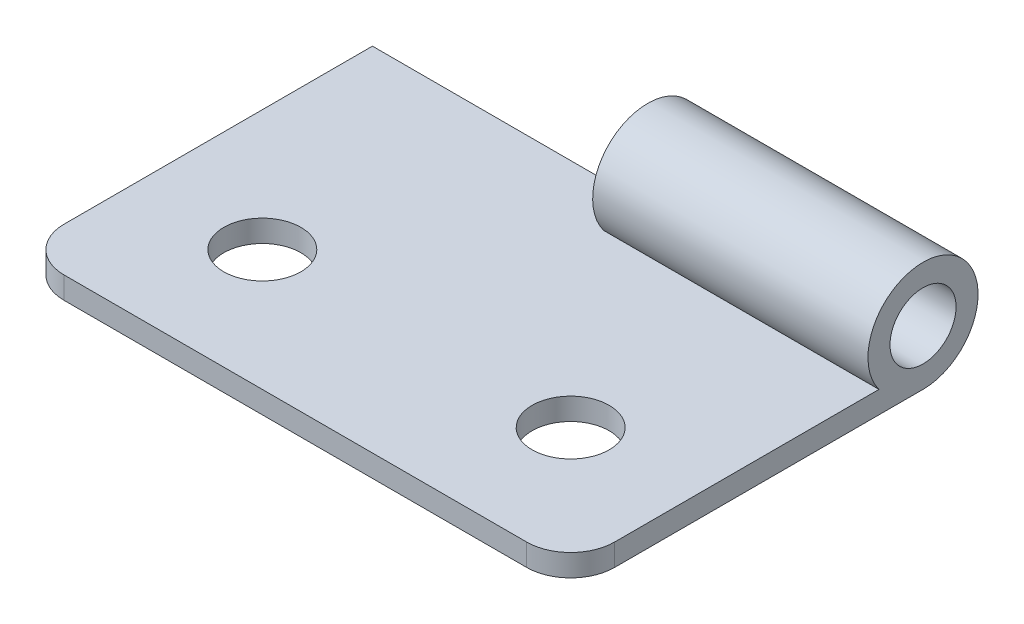
from build123d import *

# Parameters (mm, degrees)
SKETCH_1_W          = 25
SKETCH_1_H          = 16
EXTRUDE_1_DEPTH     = 1
SKETCH_2_R          = 1.75
CUT_EXTRUDE_1_DEPTH = 2
SKETCH_3_R          = 2.5
SKETCH_3_R_2        = 1.5
EXTRUDE_2_DEPTH     = 12.5
FILLET_1_R          = 2


with BuildPart() as part:
    # 草图1 → 凸台-拉伸1 (new body)
    with BuildSketch(Plane(origin=(0, 0, 0), x_dir=(1, 0, 0), z_dir=(0, 1, 0))):
        Rectangle(SKETCH_1_W, SKETCH_1_H)
    extrude(amount=EXTRUDE_1_DEPTH)

    # 草图2 → 切除-拉伸1 (cut, through all)
    with BuildSketch(Plane(origin=(0, 1, 0), x_dir=(1, 0, 0), z_dir=(0, 1, 0))):
        with Locations((-7, -2.5)):
            Circle(SKETCH_2_R)
        with Locations((7, -2.5)):
            Circle(SKETCH_2_R)
    extrude(amount=-CUT_EXTRUDE_1_DEPTH, mode=Mode.SUBTRACT)

    # 草图3 → 凸台-拉伸2 (add)
    with BuildSketch(Plane(origin=(12.5, 0, 0), x_dir=(0, 0, -1), z_dir=(1, 0, 0))):
        with Locations((8, 2.5)):
            Circle(SKETCH_3_R)
        with Locations((8, 2.5)):
            Circle(SKETCH_3_R_2, mode=Mode.SUBTRACT)
    extrude(amount=-EXTRUDE_2_DEPTH)

    # 圆角1
    fillet_1_edges = [part.edges().sort_by_distance(p)[0] for p in [
        (12.5, 0.5, 8),
        (-12.5, 0.5, 8),
    ]]
    fillet(fillet_1_edges, radius=FILLET_1_R)


solid = part.part
